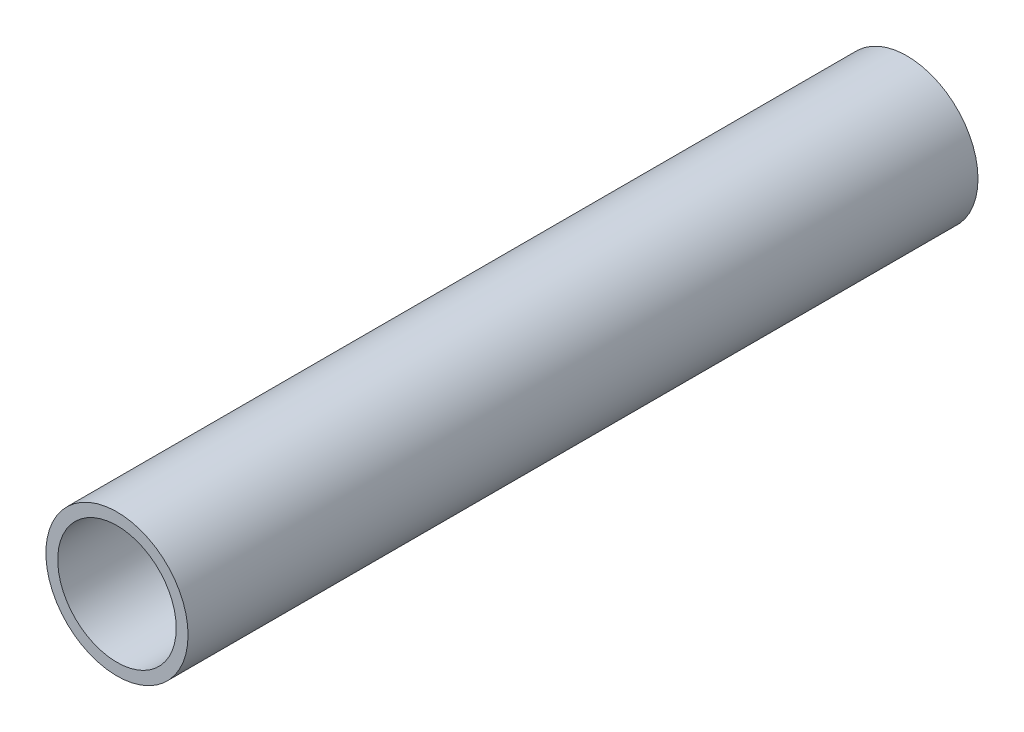
from build123d import *

# Parameters (mm, degrees)
SKETCH_1_R      = 9
SKETCH_1_R_2    = 7.5
EXTRUDE_1_DEPTH = 100


with BuildPart() as part:
    # 草图1 → 凸台-拉伸1 (new body)
    with BuildSketch(Plane.XY):
        Circle(SKETCH_1_R)
        Circle(SKETCH_1_R_2, mode=Mode.SUBTRACT)
    extrude(amount=EXTRUDE_1_DEPTH)


solid = part.part
